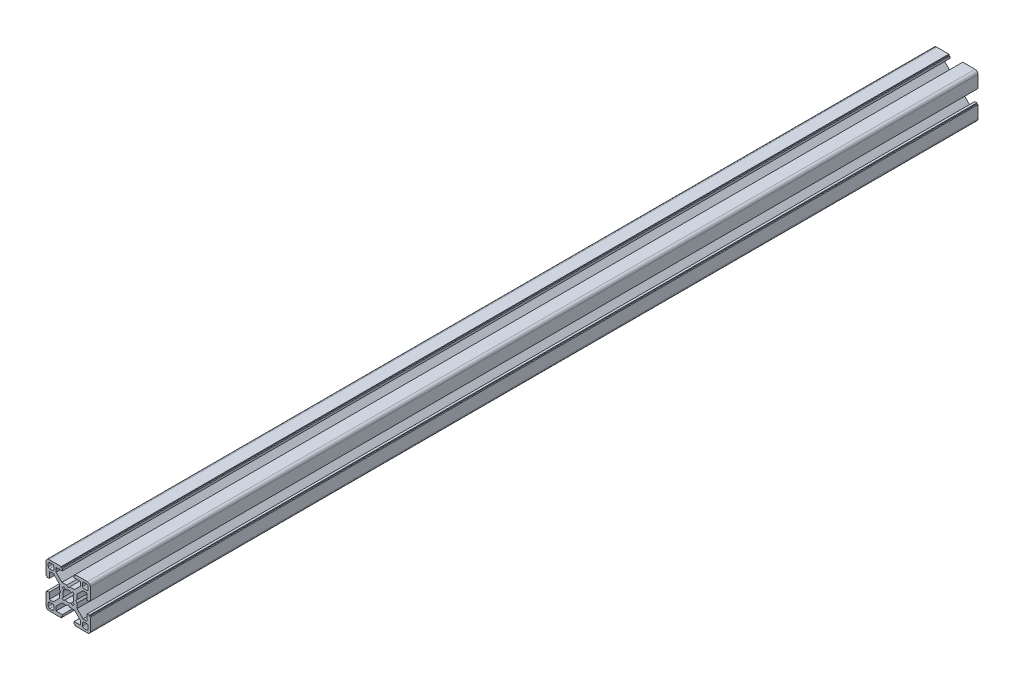
from build123d import *

# Parameters (mm, degrees)
ESTRUSIONE_ESTRUSIONE2_DEPTH = 600


with BuildPart() as part:
    # Schizzo1 → Estrusione-Estrusione2 (new body)
    with BuildSketch(Plane.XY):
        with BuildLine():
            Line((-15, 13), (-15, 4.7))
            Line((-15, 4.7), (-14.3, 4.7))
            Line((-14.3, 4.7), (-14.3, 4))
            Line((-14.3, 4), (-12.8, 4))
            Line((-12.8, 4), (-12.8, 8.25))
            Line((-12.8, 8.25), (-10.017766953, 8.25))
            Line((-10.017766953, 8.25), (-6, 4.232233047))
            Line((-6, 4.232233047), (-6, 1))
            Line((-6, 1), (-5, 0))
            Line((-5, 0), (-6, -1))
            Line((-6, -1), (-6, -4.232233047))
            Line((-6, -4.232233047), (-10.017766953, -8.25))
            Line((-10.017766953, -8.25), (-12.8, -8.25))
            Line((-12.8, -8.25), (-12.8, -4))
            Line((-12.8, -4), (-14.3, -4))
            Line((-14.3, -4), (-14.3, -4.7))
            Line((-14.3, -4.7), (-15, -4.7))
            Line((-15, -4.7), (-15, -13))
            ThreePointArc((-15, -13), (-14.414213562, -14.414213562), (-13, -15))
            Line((-13, -15), (-4.7, -15))
            Line((-4.7, -15), (-4.7, -14.3))
            Line((-4.7, -14.3), (-4, -14.3))
            Line((-4, -14.3), (-4, -12.8))
            Line((-4, -12.8), (-8.25, -12.8))
            Line((-8.25, -12.8), (-8.25, -10.017766953))
            Line((-8.25, -10.017766953), (-4.232233047, -6))
            Line((-4.232233047, -6), (-1, -6))
            Line((-1, -6), (0, -5))
            Line((0, -5), (1, -6))
            Line((1, -6), (4.232233047, -6))
            Line((4.232233047, -6), (8.25, -10.017766953))
            Line((8.25, -10.017766953), (8.25, -12.8))
            Line((8.25, -12.8), (4, -12.8))
            Line((4, -12.8), (4, -14.3))
            Line((4, -14.3), (4.7, -14.3))
            Line((4.7, -14.3), (4.7, -15))
            Line((4.7, -15), (13, -15))
            ThreePointArc((13, -15), (14.414213562, -14.414213562), (15, -13))
            Line((15, -13), (15, -4.7))
            Line((15, -4.7), (14.3, -4.7))
            Line((14.3, -4.7), (14.3, -4))
            Line((14.3, -4), (12.8, -4))
            Line((12.8, -4), (12.8, -8.25))
            Line((12.8, -8.25), (10.017766953, -8.25))
            Line((10.017766953, -8.25), (6, -4.232233047))
            Line((6, -4.232233047), (6, -1))
            Line((6, -1), (5, 0))
            Line((5, 0), (6, 1))
            Line((6, 1), (6, 4.232233047))
            Line((6, 4.232233047), (10.017766953, 8.25))
            Line((10.017766953, 8.25), (12.8, 8.25))
            Line((12.8, 8.25), (12.8, 4))
            Line((12.8, 4), (14.3, 4))
            Line((14.3, 4), (14.3, 4.7))
            Line((14.3, 4.7), (15, 4.7))
            Line((15, 4.7), (15, 13))
            ThreePointArc((15, 13), (14.414213562, 14.414213562), (13, 15))
            Line((13, 15), (4.7, 15))
            Line((4.7, 15), (4.7, 14.3))
            Line((4.7, 14.3), (4, 14.3))
            Line((4, 14.3), (4, 12.8))
            Line((4, 12.8), (8.25, 12.8))
            Line((8.25, 12.8), (8.25, 10.017766953))
            Line((8.25, 10.017766953), (4.232233047, 6))
            Line((4.232233047, 6), (1, 6))
            Line((1, 6), (0, 5))
            Line((0, 5), (-1, 6))
            Line((-1, 6), (-4.232233047, 6))
            Line((-4.232233047, 6), (-8.25, 10.017766953))
            Line((-8.25, 10.017766953), (-8.25, 12.8))
            Line((-8.25, 12.8), (-4, 12.8))
            Line((-4, 12.8), (-4, 14.3))
            Line((-4, 14.3), (-4.7, 14.3))
            Line((-4.7, 14.3), (-4.7, 15))
            Line((-4.7, 15), (-13, 15))
            ThreePointArc((-13, 15), (-14.414213562, 14.414213562), (-15, 13))
        make_face()
        with BuildLine():
            Line((13.5, 10.75), (13.5, 12.5))
            ThreePointArc((13.5, 12.5), (13.207106781, 13.207106781), (12.5, 13.5))
            Line((12.5, 13.5), (10.75, 13.5))
            ThreePointArc((10.75, 13.5), (10.042893219, 13.207106781), (9.75, 12.5))
            Line((9.75, 12.5), (9.75, 10.75))
            ThreePointArc((9.75, 10.75), (10.042893219, 10.042893219), (10.75, 9.75))
            Line((10.75, 9.75), (12.5, 9.75))
            ThreePointArc((12.5, 9.75), (13.207106781, 10.042893219), (13.5, 10.75))
        make_face(mode=Mode.SUBTRACT)
        with BuildLine():
            Line((10.75, -13.5), (12.5, -13.5))
            ThreePointArc((12.5, -13.5), (13.207106781, -13.207106781), (13.5, -12.5))
            Line((13.5, -12.5), (13.5, -10.75))
            ThreePointArc((13.5, -10.75), (13.207106781, -10.042893219), (12.5, -9.75))
            Line((12.5, -9.75), (10.75, -9.75))
            ThreePointArc((10.75, -9.75), (10.042893219, -10.042893219), (9.75, -10.75))
            Line((9.75, -10.75), (9.75, -12.5))
            ThreePointArc((9.75, -12.5), (10.042893219, -13.207106781), (10.75, -13.5))
        make_face(mode=Mode.SUBTRACT)
        with BuildLine():
            Line((-13.5, -10.75), (-13.5, -12.5))
            ThreePointArc((-13.5, -12.5), (-13.207106781, -13.207106781), (-12.5, -13.5))
            Line((-12.5, -13.5), (-10.75, -13.5))
            ThreePointArc((-10.75, -13.5), (-10.042893219, -13.207106781), (-9.75, -12.5))
            Line((-9.75, -12.5), (-9.75, -10.75))
            ThreePointArc((-9.75, -10.75), (-10.042893219, -10.042893219), (-10.75, -9.75))
            Line((-10.75, -9.75), (-12.5, -9.75))
            ThreePointArc((-12.5, -9.75), (-13.207106781, -10.042893219), (-13.5, -10.75))
        make_face(mode=Mode.SUBTRACT)
        with BuildLine():
            Line((1.995536102, 3.056196274), (3.00520382, 4.065863992))
            Line((3.00520382, 4.065863992), (4.065863992, 3.00520382))
            Line((4.065863992, 3.00520382), (3.056196274, 1.995536102))
            ThreePointArc((3.056196274, 1.995536102), (3.498400806, 1.041005187), (3.65, 0))
            ThreePointArc((3.65, 0), (3.498400806, -1.041005187), (3.056196274, -1.995536102))
            Line((3.056196274, -1.995536102), (4.065863992, -3.00520382))
            Line((4.065863992, -3.00520382), (3.00520382, -4.065863992))
            Line((3.00520382, -4.065863992), (1.995536102, -3.056196274))
            ThreePointArc((1.995536102, -3.056196274), (1.041005187, -3.498400806), (0, -3.65))
            ThreePointArc((0, -3.65), (-1.041005187, -3.498400806), (-1.995536102, -3.056196274))
            Line((-1.995536102, -3.056196274), (-3.00520382, -4.065863992))
            Line((-3.00520382, -4.065863992), (-4.065863992, -3.00520382))
            Line((-4.065863992, -3.00520382), (-3.056196274, -1.995536102))
            ThreePointArc((-3.056196274, -1.995536102), (-3.498400806, -1.041005187), (-3.65, 0))
            ThreePointArc((-3.65, 0), (-3.498400806, 1.041005187), (-3.056196274, 1.995536102))
            Line((-3.056196274, 1.995536102), (-4.065863992, 3.00520382))
            Line((-4.065863992, 3.00520382), (-3.00520382, 4.065863992))
            Line((-3.00520382, 4.065863992), (-1.995536102, 3.056196274))
            ThreePointArc((-1.995536102, 3.056196274), (-1.041005187, 3.498400806), (0, 3.65))
            ThreePointArc((0, 3.65), (1.041005187, 3.498400806), (1.995536102, 3.056196274))
        make_face(mode=Mode.SUBTRACT)
        with BuildLine():
            Line((-10.75, 9.75), (-12.5, 9.75))
            ThreePointArc((-12.5, 9.75), (-13.207106781, 10.042893219), (-13.5, 10.75))
            Line((-13.5, 10.75), (-13.5, 12.5))
            ThreePointArc((-13.5, 12.5), (-13.207106781, 13.207106781), (-12.5, 13.5))
            Line((-12.5, 13.5), (-10.75, 13.5))
            ThreePointArc((-10.75, 13.5), (-10.042893219, 13.207106781), (-9.75, 12.5))
            Line((-9.75, 12.5), (-9.75, 10.75))
            ThreePointArc((-9.75, 10.75), (-10.042893219, 10.042893219), (-10.75, 9.75))
        make_face(mode=Mode.SUBTRACT)
    extrude(amount=ESTRUSIONE_ESTRUSIONE2_DEPTH)


solid = part.part
